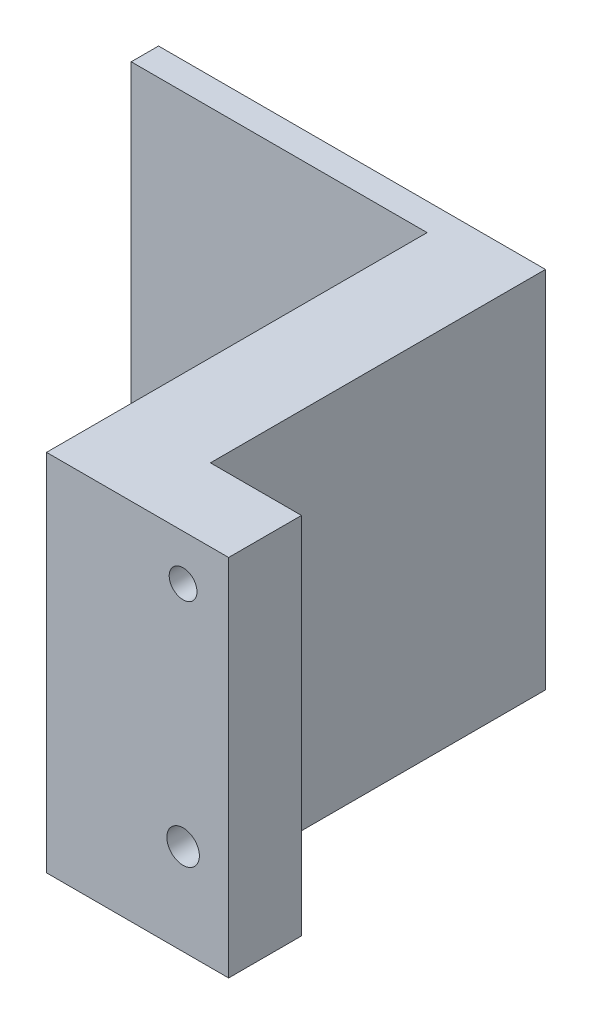
from build123d import *

# Parameters (mm, degrees)
SKETCH1_W           = 10
SKETCH1_H           = 40
BOSS_EXTRUDE1_DEPTH = 5
SKETCH1_4_W         = 10
SKETCH1_4_H         = 40
BOSS_EXTRUDE2_DEPTH = 3
BOSS_EXTRUDE3_START = 5
SKETCH1_5_W         = 10
SKETCH1_5_H         = 40
BOSS_EXTRUDE3_DEPTH = 44.8
BOSS_EXTRUDE4_START = -39.8
SKETCH1_6_W         = 22.5
SKETCH1_6_H         = 40
SKETCH1_6_R         = 1.4
SKETCH1_6_W_2       = 10
BOSS_EXTRUDE4_DEPTH = 3


with BuildPart() as part:
    # Sketch1 → Boss-Extrude1 (new body)
    with BuildSketch(Plane.XY):
        Polygon((54.918901731, 32.442311257), (49.918901731, 32.442311257), (49.918901731, 30.44249106), (51.6180048, 30.461093919), (53.382795739, 27.480236167), (51.683692671, 24.461453505), (49.918901731, 24.442131453), (49.918901731, 5.44249106), (51.683692671, 5.423169009), (53.382795739, 2.404386347), (51.6180048, -0.576471406), (49.918901731, -0.557868547), (49.918901731, -7.557688743), (54.918901731, -7.557688743), align=None)
        Polygon((49.918901731, 32.442311257), (44.918901731, 32.442311257), (44.918901731, -7.557688743), (49.918901731, -7.557688743), (49.918901731, -0.557868547), (48.154110791, -0.538546495), (46.455007723, 2.480236167), (48.219798662, 5.461093919), (49.918901731, 5.44249106), (49.918901731, 24.442131453), (48.219798662, 24.423528594), (46.455007723, 27.404386347), (48.154110791, 30.423169009), (49.918901731, 30.44249106), align=None)
        with BuildLine():
            Line((49.918901731, 0.655890403), (49.918901731, -0.557868547))
            Line((49.918901731, -0.557868547), (51.6180048, -0.576471406))
            Line((51.6180048, -0.576471406), (53.382795739, 2.404386347))
            Line((53.382795739, 2.404386347), (51.683692671, 5.423169009))
            Line((51.683692671, 5.423169009), (49.918901731, 5.44249106))
            Line((49.918901731, 5.44249106), (49.918901731, 4.22873211))
            ThreePointArc((49.918901731, 4.22873211), (51.182092031, 3.705501556), (51.705322585, 2.442311257))
            ThreePointArc((51.705322585, 2.442311257), (51.182092031, 1.179120957), (49.918901731, 0.655890403))
        make_face()
        with BuildLine():
            Line((48.154110791, -0.538546495), (49.918901731, -0.557868547))
            Line((49.918901731, -0.557868547), (49.918901731, 0.655890403))
            ThreePointArc((49.918901731, 0.655890403), (48.132480877, 2.442311257), (49.918901731, 4.22873211))
            Line((49.918901731, 4.22873211), (49.918901731, 5.44249106))
            Line((49.918901731, 5.44249106), (48.219798662, 5.461093919))
            Line((48.219798662, 5.461093919), (46.455007723, 2.480236167))
            Line((46.455007723, 2.480236167), (48.154110791, -0.538546495))
        make_face()
        with BuildLine():
            Line((51.6180048, 30.461093919), (49.918901731, 30.44249106))
            Line((49.918901731, 30.44249106), (49.918901731, 28.967240827))
            ThreePointArc((49.918901731, 28.967240827), (50.997189771, 28.520599297), (51.443831301, 27.442311257))
            ThreePointArc((51.443831301, 27.442311257), (50.997189771, 26.364023217), (49.918901731, 25.917381686))
            Line((49.918901731, 25.917381686), (49.918901731, 24.442131453))
            Line((49.918901731, 24.442131453), (51.683692671, 24.461453505))
            Line((51.683692671, 24.461453505), (53.382795739, 27.480236167))
            Line((53.382795739, 27.480236167), (51.6180048, 30.461093919))
        make_face()
        with BuildLine():
            Line((49.918901731, 28.967240827), (49.918901731, 30.44249106))
            Line((49.918901731, 30.44249106), (48.154110791, 30.423169009))
            Line((48.154110791, 30.423169009), (46.455007723, 27.404386347))
            Line((46.455007723, 27.404386347), (48.219798662, 24.423528594))
            Line((48.219798662, 24.423528594), (49.918901731, 24.442131453))
            Line((49.918901731, 24.442131453), (49.918901731, 25.917381686))
            ThreePointArc((49.918901731, 25.917381686), (48.39397216, 27.442311257), (49.918901731, 28.967240827))
        make_face()
        with Locations((39.918901731, 12.442311257)):
            Rectangle(SKETCH1_W, SKETCH1_H)
    extrude(amount=BOSS_EXTRUDE1_DEPTH)

    # Sketch1_4 → Boss-Extrude2 (add)
    with BuildSketch(Plane.XY):
        Polygon((49.918901731, 32.442311257), (44.918901731, 32.442311257), (44.918901731, -7.557688743), (49.918901731, -7.557688743), (49.918901731, -0.557868547), (48.154110791, -0.538546495), (46.455007723, 2.480236167), (48.219798662, 5.461093919), (49.918901731, 5.44249106), (49.918901731, 24.442131453), (48.219798662, 24.423528594), (46.455007723, 27.404386347), (48.154110791, 30.423169009), (49.918901731, 30.44249106), align=None)
        Polygon((54.918901731, 32.442311257), (49.918901731, 32.442311257), (49.918901731, 30.44249106), (51.6180048, 30.461093919), (53.382795739, 27.480236167), (51.683692671, 24.461453505), (49.918901731, 24.442131453), (49.918901731, 5.44249106), (51.683692671, 5.423169009), (53.382795739, 2.404386347), (51.6180048, -0.576471406), (49.918901731, -0.557868547), (49.918901731, -7.557688743), (54.918901731, -7.557688743), align=None)
        with Locations((39.918901731, 12.442311257)):
            Rectangle(SKETCH1_4_W, SKETCH1_4_H)
    extrude(amount=-BOSS_EXTRUDE2_DEPTH)

    # Sketch1_5 → Boss-Extrude3 (add)
    with BuildSketch(Plane.XY.offset(BOSS_EXTRUDE3_START)):
        with Locations((39.918901731, 12.442311257)):
            Rectangle(SKETCH1_5_W, SKETCH1_5_H)
    extrude(amount=-BOSS_EXTRUDE3_DEPTH)

    # Sketch1_6 → Boss-Extrude4 (add)
    with BuildSketch(Plane.XY.offset(BOSS_EXTRUDE4_START)):
        with Locations((13.668901731, 12.442311257)):
            Rectangle(SKETCH1_6_W, SKETCH1_6_H)
        with Locations((13.668901731, -2.557688743)):
            Circle(SKETCH1_6_R, mode=Mode.SUBTRACT)
        with Locations((13.668901731, 7.442311257)):
            Circle(SKETCH1_6_R, mode=Mode.SUBTRACT)
        with Locations((29.918901731, 12.442311257)):
            Rectangle(SKETCH1_6_W_2, SKETCH1_6_H)
    extrude(amount=BOSS_EXTRUDE4_DEPTH)


solid = part.part
